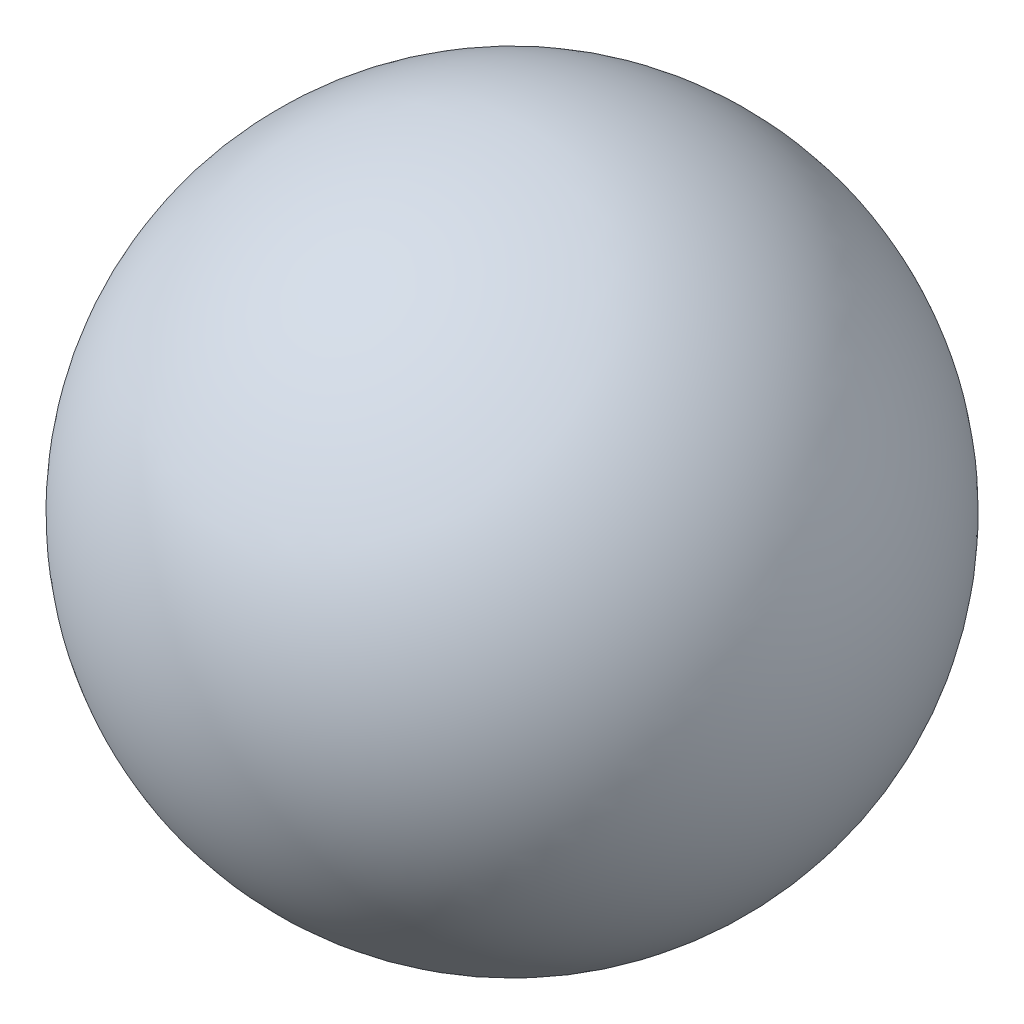
from build123d import *


with BuildPart() as part:
    # Sketch1 → Revolve1 (revolve)
    with BuildSketch(Plane(origin=(0, 0, 0), x_dir=(1, 0, 0), z_dir=(0, 1, 0))):
        with BuildLine():
            Line((0, -6.35), (0, 6.35))
            ThreePointArc((0, 6.35), (-6.35, 0), (0, -6.35))
        make_face()
    revolve(axis=Axis((0, 0, 6.35), (0, 0, -1)))


solid = part.part
